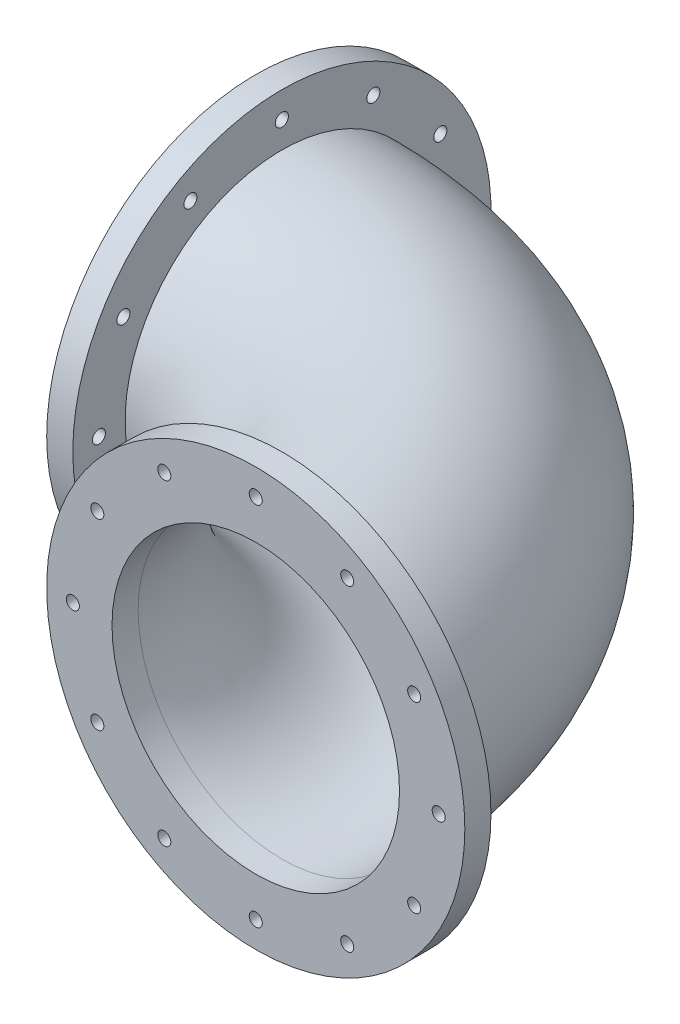
from build123d import *

# Parameters (mm, degrees)
SKETCH2_R           = 76.2
SKETCH2_R_2         = 69.85
SKETCH3_R           = 101.6
SKETCH3_R_2         = 69.85
SKETCH3_R_3         = 3.175
BOSS_EXTRUDE1_DEPTH = 12.7
SKETCH5_R           = 101.6
SKETCH5_R_2         = 69.85
SKETCH5_R_3         = 3.175
BOSS_EXTRUDE2_DEPTH = 12.7


with BuildPart() as part:
    # Sweep1: sweep along a path in Sketch1
    with BuildLine(Plane(origin=(0, 0, 0), x_dir=(1, 0, 0), z_dir=(0, 1, 0))) as sweep1_path:
        ThreePointArc((0, 152.4), (107.763073453, 107.763073453), (152.4, 0))
    # Sketch2 → Sweep1 (sweep)
    with BuildSketch(Plane(origin=(0, 0, 0), x_dir=(0, 0, -1), z_dir=(1, 0, 0))):
        with Locations((152.4, 0)):
            Circle(SKETCH2_R)
        with Locations((152.4, 0)):
            Circle(SKETCH2_R_2, mode=Mode.SUBTRACT)
    sweep(path=sweep1_path.line)

    # Sketch3 → Boss-Extrude1 (add)
    with BuildSketch(Plane.ZY):
        with Locations((-152.4, 0)):
            Circle(SKETCH3_R)
        with Locations((-152.4, 0)):
            Circle(SKETCH3_R_2, mode=Mode.SUBTRACT)
        with Locations((-241.3, 0)):
            Circle(SKETCH3_R_3, mode=Mode.SUBTRACT)
        with Locations((-229.389658396, -44.45)):
            Circle(SKETCH3_R_3, mode=Mode.SUBTRACT)
        with Locations((-196.85, -76.989658396)):
            Circle(SKETCH3_R_3, mode=Mode.SUBTRACT)
        with Locations((-152.4, -88.9)):
            Circle(SKETCH3_R_3, mode=Mode.SUBTRACT)
        with Locations((-107.95, -76.989658396)):
            Circle(SKETCH3_R_3, mode=Mode.SUBTRACT)
        with Locations((-75.410341604, -44.45)):
            Circle(SKETCH3_R_3, mode=Mode.SUBTRACT)
        with Locations((-63.5, 0)):
            Circle(SKETCH3_R_3, mode=Mode.SUBTRACT)
        with Locations((-75.410341604, 44.45)):
            Circle(SKETCH3_R_3, mode=Mode.SUBTRACT)
        with Locations((-107.95, 76.989658396)):
            Circle(SKETCH3_R_3, mode=Mode.SUBTRACT)
        with Locations((-152.4, 88.9)):
            Circle(SKETCH3_R_3, mode=Mode.SUBTRACT)
        with Locations((-196.85, 76.989658396)):
            Circle(SKETCH3_R_3, mode=Mode.SUBTRACT)
        with Locations((-229.389658396, 44.45)):
            Circle(SKETCH3_R_3, mode=Mode.SUBTRACT)
    extrude(amount=BOSS_EXTRUDE1_DEPTH)

    # Sketch5 → Boss-Extrude2 (add)
    with BuildSketch(Plane.XY):
        with Locations((152.4, 0)):
            Circle(SKETCH5_R)
        with Locations((152.4, 0)):
            Circle(SKETCH5_R_2, mode=Mode.SUBTRACT)
        with Locations((152.4, 88.9)):
            Circle(SKETCH5_R_3, mode=Mode.SUBTRACT)
        with Locations((196.85, 76.989658396)):
            Circle(SKETCH5_R_3, mode=Mode.SUBTRACT)
        with Locations((229.389658396, 44.45)):
            Circle(SKETCH5_R_3, mode=Mode.SUBTRACT)
        with Locations((241.3, 0)):
            Circle(SKETCH5_R_3, mode=Mode.SUBTRACT)
        with Locations((229.389658396, -44.45)):
            Circle(SKETCH5_R_3, mode=Mode.SUBTRACT)
        with Locations((196.85, -76.989658396)):
            Circle(SKETCH5_R_3, mode=Mode.SUBTRACT)
        with Locations((152.4, -88.9)):
            Circle(SKETCH5_R_3, mode=Mode.SUBTRACT)
        with Locations((107.95, -76.989658396)):
            Circle(SKETCH5_R_3, mode=Mode.SUBTRACT)
        with Locations((75.410341604, -44.45)):
            Circle(SKETCH5_R_3, mode=Mode.SUBTRACT)
        with Locations((63.5, 0)):
            Circle(SKETCH5_R_3, mode=Mode.SUBTRACT)
        with Locations((75.410341604, 44.45)):
            Circle(SKETCH5_R_3, mode=Mode.SUBTRACT)
        with Locations((107.95, 76.989658396)):
            Circle(SKETCH5_R_3, mode=Mode.SUBTRACT)
    extrude(amount=BOSS_EXTRUDE2_DEPTH)


solid = part.part
